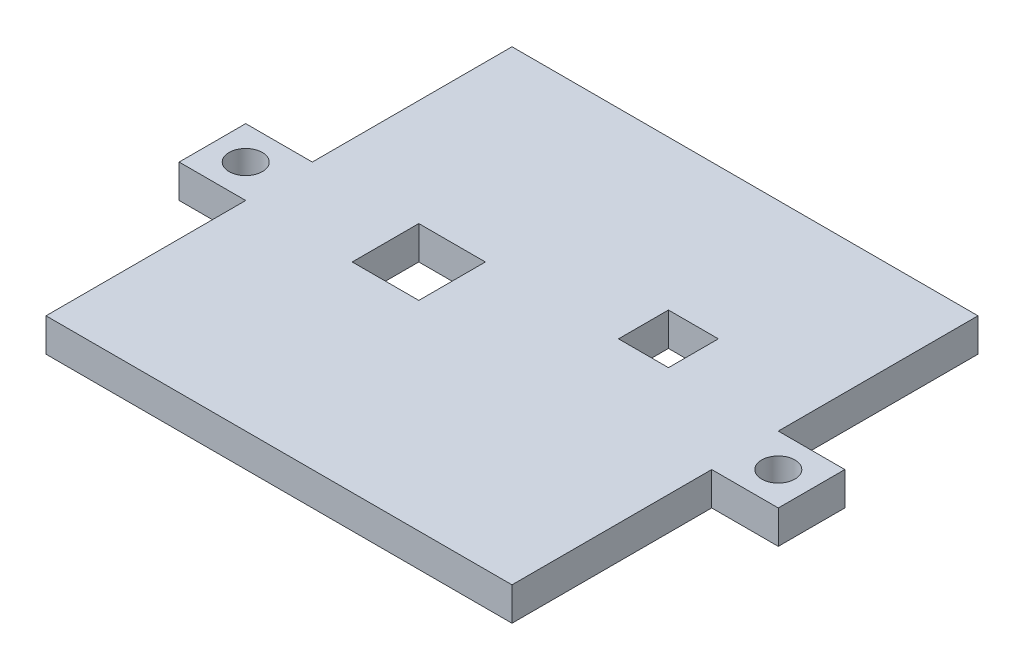
from build123d import *

# Parameters (mm, degrees)
SKETCH1_W           = 88.9
SKETCH1_H           = 88.9
BOSS_EXTRUDE1_DEPTH = 6.35
SKETCH3_W           = 12.7
SKETCH3_H           = 12.7
BOSS_EXTRUDE3_DEPTH = 6.35
SKETCH4_R           = 3.175
CUT_EXTRUDE1_DEPTH  = 7.35
SKETCH6_W           = 12.7
SKETCH6_H           = 12.7
SKETCH6_W_2         = 9.525
SKETCH6_H_2         = 9.525
CUT_EXTRUDE2_DEPTH  = 6.35


with BuildPart() as part:
    # Sketch1 → Boss-Extrude1 (new body)
    with BuildSketch(Plane(origin=(0, 0, 0), x_dir=(1, 0, 0), z_dir=(0, 1, 0))):
        with Locations((38.1, 38.1)):
            Rectangle(SKETCH1_W, SKETCH1_H)
    extrude(amount=BOSS_EXTRUDE1_DEPTH)

    # Sketch3 → Boss-Extrude3 (add)
    with BuildSketch(Plane(origin=(0, 6.35, 0), x_dir=(1, 0, 0), z_dir=(0, 1, 0))):
        with Locations((88.9, 38.1)):
            Rectangle(SKETCH3_W, SKETCH3_H)
        with Locations((-12.7, 38.1)):
            Rectangle(SKETCH3_W, SKETCH3_H)
    extrude(amount=-BOSS_EXTRUDE3_DEPTH)

    # Sketch4 → Cut-Extrude1 (cut, through all)
    with BuildSketch(Plane(origin=(0, 6.35, 0), x_dir=(1, 0, 0), z_dir=(0, 1, 0))):
        with Locations((88.9, 38.1)):
            Circle(SKETCH4_R)
        with Locations((-12.7, 38.1)):
            Circle(SKETCH4_R)
    extrude(amount=-CUT_EXTRUDE1_DEPTH, mode=Mode.SUBTRACT)

    # Sketch6 → Cut-Extrude2 (cut)
    with BuildSketch(Plane(origin=(0, 6.35, 0), x_dir=(1, 0, 0), z_dir=(0, 1, 0))):
        with Locations((20.32, 38.1)):
            Rectangle(SKETCH6_W, SKETCH6_H)
        with Locations((56.8325, 49.2125)):
            Rectangle(SKETCH6_W_2, SKETCH6_H_2)
    extrude(amount=-CUT_EXTRUDE2_DEPTH, mode=Mode.SUBTRACT)


solid = part.part
